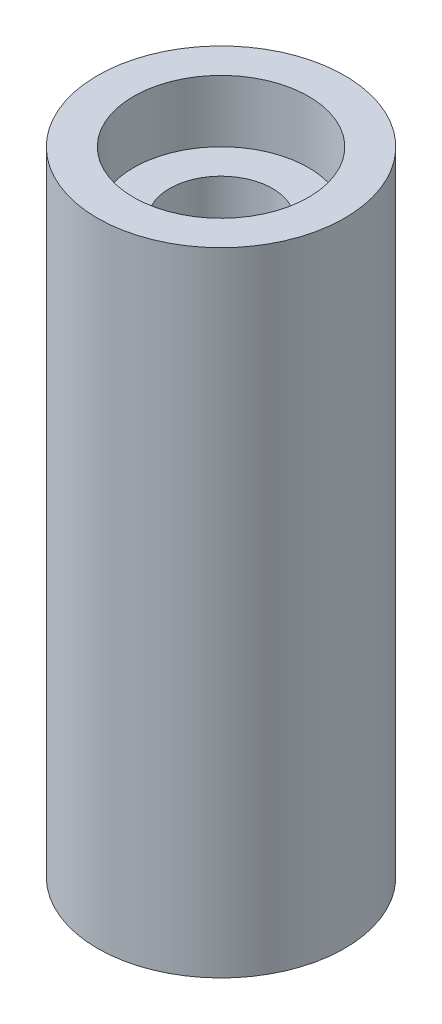
from build123d import *

# Parameters (mm, degrees)
BOSS_EXTRUDE1_DEPTH      = 97.5
BOSS_EXTRUDE1_DEPTH_BACK = 97.5
SKETCH1_R                = 38.1
SKETCH2_R                = 26.9875
CUT_EXTRUDE1_DEPTH       = 19.05
SKETCH3_R                = 15.875
CUT_EXTRUDE2_DEPTH       = 185.015277898


with BuildPart() as part:
    # Sketch1 → Boss-Extrude1 (new, two sides: drawn at the far end of the back side and taken through both)
    with BuildSketch(Plane(origin=(0, 0, 0), x_dir=(1, 0, 0), z_dir=(0, 1, 0)).offset(-BOSS_EXTRUDE1_DEPTH_BACK)):
        Circle(SKETCH1_R)
    extrude(amount=BOSS_EXTRUDE1_DEPTH + BOSS_EXTRUDE1_DEPTH_BACK)

    # Sketch2 → Cut-Extrude1 (cut)
    with BuildSketch(Plane(origin=(0, 97.5, 0), x_dir=(1, 0, 0), z_dir=(0, 1, 0))):
        Circle(SKETCH2_R)
    cut_extrude1 = extrude(amount=-CUT_EXTRUDE1_DEPTH, mode=Mode.SUBTRACT)

    # Mirror1: Cut-Extrude1 across plane
    add(cut_extrude1.mirror(Plane.ZX), mode=Mode.SUBTRACT)

    # Sketch3 → Cut-Extrude2 (cut, through all)
    with BuildSketch(Plane(origin=(0, 78.45, 0), x_dir=(1, 0, 0), z_dir=(0, 1, 0))):
        Circle(SKETCH3_R)
    extrude(amount=-CUT_EXTRUDE2_DEPTH, mode=Mode.SUBTRACT)


solid = part.part
